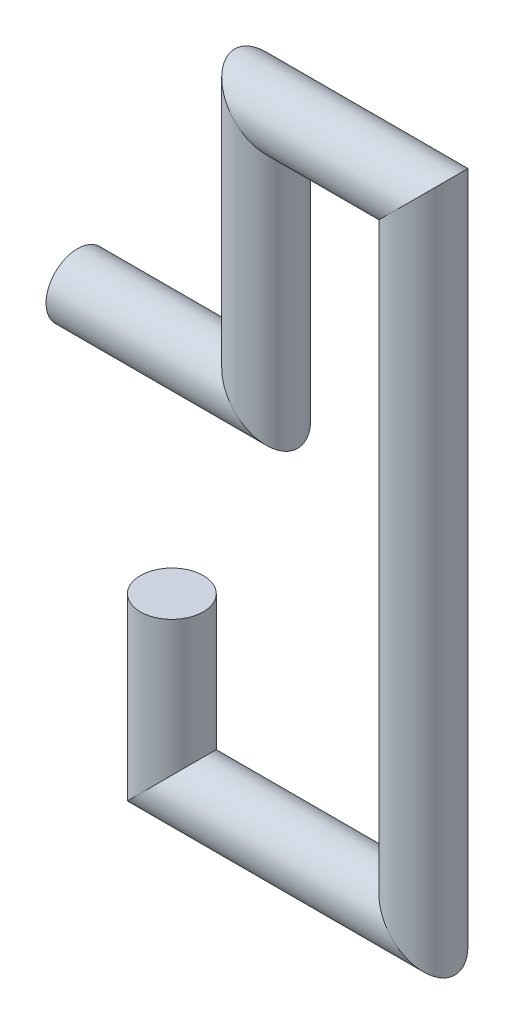
from build123d import *

# Parameters (mm, degrees)
SKETCH_2_R = 10


with BuildPart() as part:
    # 스윕1: sweep along a path in 스케치1
    with BuildLine(Plane.XY) as sweep_1_path:
        Line((0, 0), (60, 0))
        Line((60, 0), (60, 80))
        Line((60, 80), (110, 80))
        Line((110, 80), (110, -120))
        Line((110, -120), (30, -120))
        Line((30, -120), (30, -70))
    # 스케치2 → 스윕1 (sweep)
    with BuildSketch(Plane(origin=(0, 0, 0), x_dir=(0, 0, -1), z_dir=(1, 0, 0))):
        Circle(SKETCH_2_R)
    sweep(path=sweep_1_path.line, transition=Transition.RIGHT)


solid = part.part
